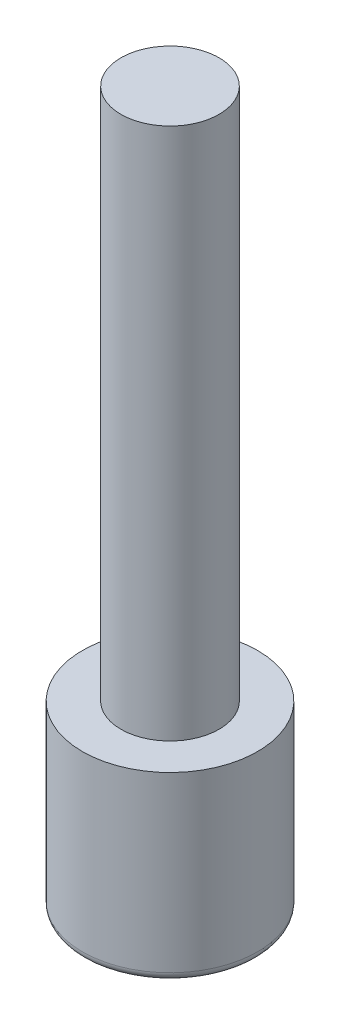
from build123d import *

# Parameters (mm, degrees)
FILLET1_R = 0.25


with BuildPart() as part:
    # Sketch2 → Revolve1 (revolve)
    with BuildSketch(Plane(origin=(0, 0, 0), x_dir=(0, 0, -1), z_dir=(1, 0, 0))):
        Polygon((0, 0), (2.5, 0), (2.5, 5.2), (1.4, 5.2), (1.4, 20.4), (0, 20.4), align=None)
    revolve(axis=Axis((0, 20.4, 0), (0, -1, 0)))

    # Fillet1
    fillet1_edges = [part.edges().sort_by_distance(p)[0] for p in [
        (0, 0, 2.5),
    ]]
    fillet(fillet1_edges, radius=FILLET1_R)


solid = part.part
